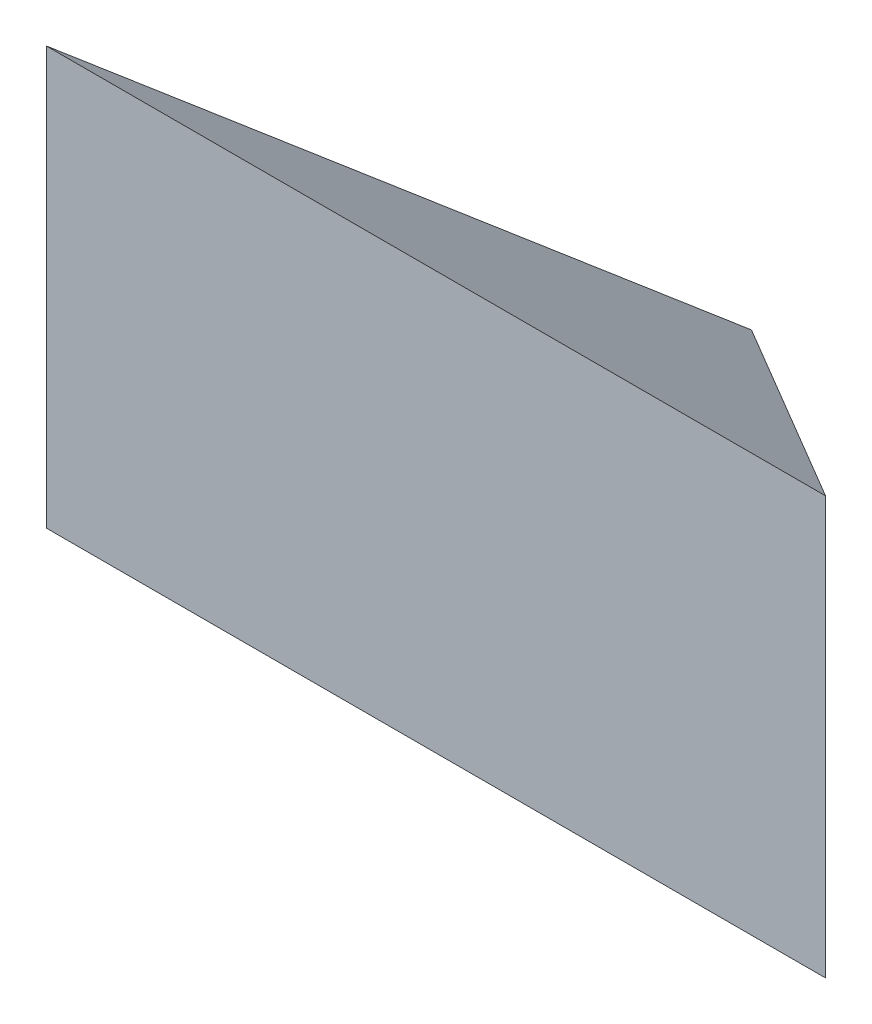
from build123d import *

# Parameters (mm, degrees)
BOSS_EXTRUDE1_DEPTH = 90.101349
CUT_EXTRUDE3_DEPTH  = 257.717103907
CUT_EXTRUDE4_DEPTH  = 202.563222837


with BuildPart() as part:
    # 3DSketch1 → Boss-Extrude1 (new body)
    with BuildSketch(Plane(origin=(-103.731361149, 50.299698024, -48.298204463), x_dir=(0.8813808665660824, -0.4724063590291962, 0), z_dir=(0, 0, 1))):
        Polygon((0, 0), (182.853673959, 98.006709275), (235.383737233, 0), (52.530063274, -98.006709275), align=None)
    extrude(amount=-BOSS_EXTRUDE1_DEPTH)

    # Sketch3 → Cut-Extrude3 (cut, through all)
    with BuildSketch(Plane.ZY.offset(103.731361149)):
        Polygon((-48.298204463, 50.299698024), (-132.298204463, -5.298689116), (-48.298204463, -60.897076257), (-138.399553935, -60.897076257), (-138.399553935, 50.299698024), align=None)
    extrude(amount=-CUT_EXTRUDE3_DEPTH, mode=Mode.SUBTRACT)

    # Sketch2 → Cut-Extrude4 (cut, through all)
    with BuildSketch(Plane(origin=(0, 50.299698024, 0), x_dir=(1, 0, 0), z_dir=(0, 1, 0))):
        Polygon((-103.731361149, 48.298204463), (0, 132.298204463), (103.731361149, 48.298204463), (103.731361149, 138.399553935), (-103.731361149, 138.399553935), align=None)
    extrude(amount=-CUT_EXTRUDE4_DEPTH, mode=Mode.SUBTRACT)


solid = part.part
